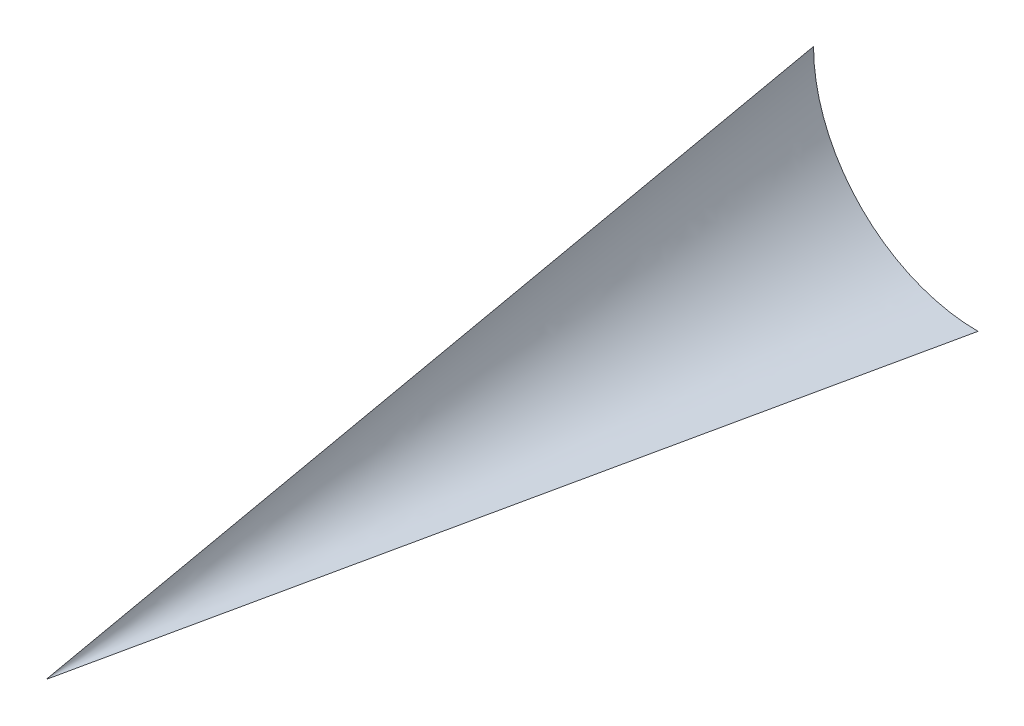
from build123d import *


with BuildPart() as part:
    # Esquisse1 → Lissage1 section 0
    with BuildSketch(Plane.XY, mode=Mode.PRIVATE) as lissage1_s0:
        with BuildLine():
            Line((0, 15), (0, 0))
            Line((0, 0), (15, 0))
            ThreePointArc((15, 0), (4.393398282, 4.393398282), (0, 15))
        make_face()
    loft([Vertex(0, 0, 70), lissage1_s0.sketch])


solid = part.part
